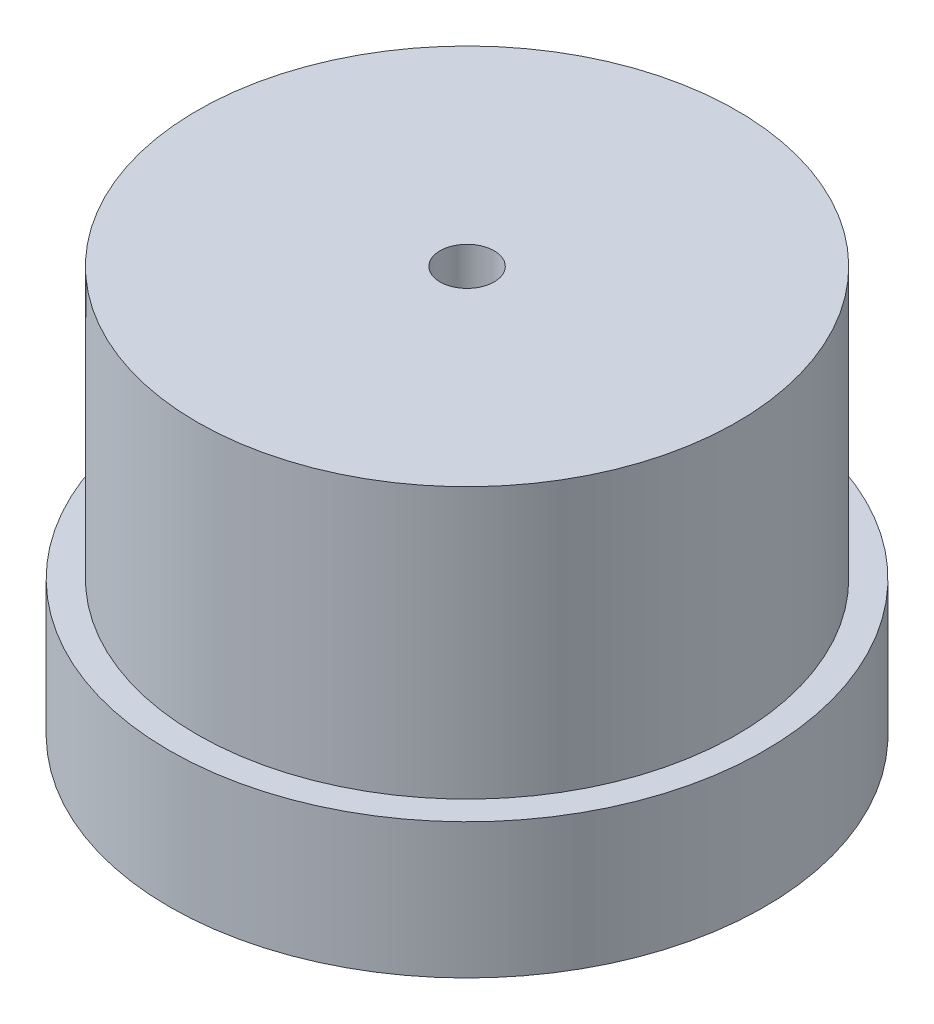
from build123d import *

# Parameters (mm, degrees)
SKETCH1_R           = 22
BOSS_EXTRUDE2_DEPTH = 10
SKETCH2_R           = 19.95
BOSS_EXTRUDE3_DEPTH = 20
SKETCH3_R           = 2
CUT_EXTRUDE1_DEPTH  = 31


with BuildPart() as part:
    # Sketch1 → Boss-Extrude2 (new body)
    with BuildSketch(Plane(origin=(0, 0, 0), x_dir=(1, 0, 0), z_dir=(0, 1, 0))):
        Circle(SKETCH1_R)
    extrude(amount=BOSS_EXTRUDE2_DEPTH)

    # Sketch2 → Boss-Extrude3 (add)
    with BuildSketch(Plane(origin=(0, 10, 0), x_dir=(1, 0, 0), z_dir=(0, 1, 0))):
        Circle(SKETCH2_R)
    extrude(amount=BOSS_EXTRUDE3_DEPTH)

    # Sketch3 → Cut-Extrude1 (cut, through all)
    with BuildSketch(Plane(origin=(0, 30, 0), x_dir=(1, 0, 0), z_dir=(0, 1, 0))):
        Circle(SKETCH3_R)
    extrude(amount=-CUT_EXTRUDE1_DEPTH, mode=Mode.SUBTRACT)


solid = part.part
